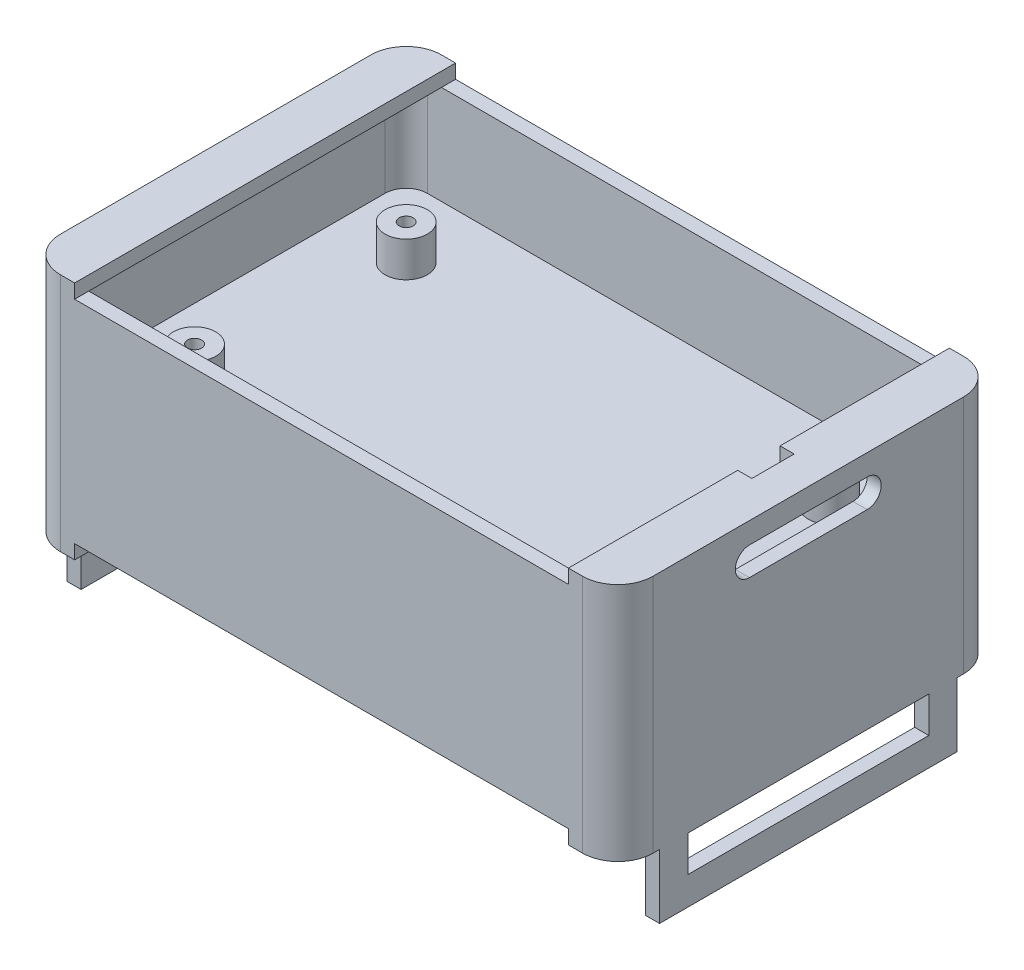
from build123d import *

# Parameters (mm, degrees)
EXTRUDE_THIN1_DEPTH      = 15
EXTRUDE_THIN1_DEPTH_BACK = 15
BOSS_EXTRUDE1_DEPTH      = 1
SKETCH3_R                = 3
SKETCH3_R_2              = 1
BOSS_EXTRUDE2_DEPTH      = 5
BOSS_EXTRUDE3_DEPTH      = 2
BOSS_EXTRUDE4_START      = -30
BOSS_EXTRUDE4_DEPTH      = 2
SKETCH5_W                = 34.167254682
SKETCH5_H                = 5.095662734
BOSS_EXTRUDE5_DEPTH      = 2
BOSS_EXTRUDE6_START      = -84
SKETCH5_3_W              = 34.167254682
SKETCH5_3_H              = 5.095662734
BOSS_EXTRUDE6_DEPTH      = 2
CUT_EXTRUDE1_DEPTH       = 85


with BuildPart() as part:
    # Sketch1 → Extrude-Thin1 (new body, two sides)
    with BuildSketch(Plane(origin=(0, 0, 0), x_dir=(1, 0, 0), z_dir=(0, 1, 0))) as extrude_thin1_sk:
        with BuildLine():
            Line((-42, 22), (-42, -22))
            ThreePointArc((-42, -22), (-40.535533906, -25.535533906), (-37, -27))
            Line((-37, -27), (37, -27))
            ThreePointArc((37, -27), (40.535533906, -25.535533906), (42, -22))
            Line((42, -22), (42, 22))
            ThreePointArc((42, 22), (40.535533906, 25.535533906), (37, 27))
            Line((37, 27), (-37, 27))
            ThreePointArc((-37, 27), (-40.535533906, 25.535533906), (-42, 22))
        make_face()
        with BuildLine():
            Line((-40, 22), (-40, -22))
            ThreePointArc((-40, -22), (-39.121320344, -24.121320344), (-37, -25))
            Line((-37, -25), (37, -25))
            ThreePointArc((37, -25), (39.121320344, -24.121320344), (40, -22))
            Line((40, -22), (40, 22))
            ThreePointArc((40, 22), (39.121320344, 24.121320344), (37, 25))
            Line((37, 25), (-37, 25))
            ThreePointArc((-37, 25), (-39.121320344, 24.121320344), (-40, 22))
        make_face(mode=Mode.SUBTRACT)
    extrude(amount=EXTRUDE_THIN1_DEPTH)
    extrude(extrude_thin1_sk.sketch, amount=-EXTRUDE_THIN1_DEPTH_BACK)

    # Sketch1_2 → Boss-Extrude1 (add)
    with BuildSketch(Plane(origin=(0, 0, 0), x_dir=(1, 0, 0), z_dir=(0, 1, 0))):
        with BuildLine():
            Line((-37, -25), (37, -25))
            ThreePointArc((37, -25), (39.121320344, -24.121320344), (40, -22))
            Line((40, -22), (40, 22))
            ThreePointArc((40, 22), (39.121320344, 24.121320344), (37, 25))
            Line((37, 25), (-37, 25))
            ThreePointArc((-37, 25), (-39.121320344, 24.121320344), (-40, 22))
            Line((-40, 22), (-40, -22))
            ThreePointArc((-40, -22), (-39.121320344, -24.121320344), (-37, -25))
        make_face()
    extrude(amount=BOSS_EXTRUDE1_DEPTH)

    # Sketch3 → Boss-Extrude2 (add)
    with BuildSketch(Plane(origin=(0, 1, 0), x_dir=(1, 0, 0), z_dir=(0, 1, 0))):
        with Locations((-30, 15)):
            Circle(SKETCH3_R)
        with Locations((-30, 15)):
            Circle(SKETCH3_R_2, mode=Mode.SUBTRACT)
        with Locations((30, 15)):
            Circle(SKETCH3_R)
        with Locations((30, 15)):
            Circle(SKETCH3_R_2, mode=Mode.SUBTRACT)
        with Locations((30, -15)):
            Circle(SKETCH3_R)
        with Locations((30, -15)):
            Circle(SKETCH3_R_2, mode=Mode.SUBTRACT)
        with Locations((-30, -15)):
            Circle(SKETCH3_R)
        with Locations((-30, -15)):
            Circle(SKETCH3_R_2, mode=Mode.SUBTRACT)
    extrude(amount=BOSS_EXTRUDE2_DEPTH)

    # Sketch4 → Boss-Extrude3 (add)
    with BuildSketch(Plane(origin=(0, 15, 0), x_dir=(1, 0, 0), z_dir=(0, 1, 0))):
        with BuildLine():
            Line((-35, 25), (-35, 27))
            Line((-35, 27), (-37, 27))
            ThreePointArc((-37, 27), (-40.535533906, 25.535533906), (-42, 22))
            Line((-42, 22), (-42, -22))
            ThreePointArc((-42, -22), (-40.535533906, -25.535533906), (-37, -27))
            Line((-37, -27), (-35, -27))
            Line((-35, -27), (-35, -25))
            Line((-35, -25), (-37, -25))
            ThreePointArc((-37, -25), (-39.121320344, -24.121320344), (-40, -22))
            Line((-40, -22), (-40, 22))
            ThreePointArc((-40, 22), (-39.121320344, 24.121320344), (-37, 25))
            Line((-37, 25), (-35, 25))
        make_face()
        with BuildLine():
            Line((-35, -25), (-35, 25))
            Line((-35, 25), (-37, 25))
            ThreePointArc((-37, 25), (-39.121320344, 24.121320344), (-40, 22))
            Line((-40, 22), (-40, -22))
            ThreePointArc((-40, -22), (-39.121320344, -24.121320344), (-37, -25))
            Line((-37, -25), (-35, -25))
        make_face()
        with BuildLine():
            Line((37, 25), (35, 25))
            Line((35, 25), (35, 3))
            Line((35, 3), (37, 3))
            Line((37, 3), (37, -3))
            Line((37, -3), (35, -3))
            Line((35, -3), (35, -25))
            Line((35, -25), (37, -25))
            ThreePointArc((37, -25), (39.121320344, -24.121320344), (40, -22))
            Line((40, -22), (40, 22))
            ThreePointArc((40, 22), (39.121320344, 24.121320344), (37, 25))
        make_face()
        with BuildLine():
            Line((37, 27), (35, 27))
            Line((35, 27), (35, 25))
            Line((35, 25), (37, 25))
            ThreePointArc((37, 25), (39.121320344, 24.121320344), (40, 22))
            Line((40, 22), (40, -22))
            ThreePointArc((40, -22), (39.121320344, -24.121320344), (37, -25))
            Line((37, -25), (35, -25))
            Line((35, -25), (35, -27))
            Line((35, -27), (37, -27))
            ThreePointArc((37, -27), (40.535533906, -25.535533906), (42, -22))
            Line((42, -22), (42, 22))
            ThreePointArc((42, 22), (40.535533906, 25.535533906), (37, 27))
        make_face()
    extrude(amount=BOSS_EXTRUDE3_DEPTH)

    # Sketch4_3 → Boss-Extrude4 (add)
    with BuildSketch(Plane(origin=(0, 15, 0), x_dir=(1, 0, 0), z_dir=(0, 1, 0)).offset(BOSS_EXTRUDE4_START)):
        with BuildLine():
            Line((-35, -25), (-35, 25))
            Line((-35, 25), (-37, 25))
            ThreePointArc((-37, 25), (-39.121320344, 24.121320344), (-40, 22))
            Line((-40, 22), (-40, -22))
            ThreePointArc((-40, -22), (-39.121320344, -24.121320344), (-37, -25))
            Line((-37, -25), (-35, -25))
        make_face()
        with BuildLine():
            Line((-35, 25), (-35, 27))
            Line((-35, 27), (-37, 27))
            ThreePointArc((-37, 27), (-40.535533906, 25.535533906), (-42, 22))
            Line((-42, 22), (-42, -22))
            ThreePointArc((-42, -22), (-40.535533906, -25.535533906), (-37, -27))
            Line((-37, -27), (-35, -27))
            Line((-35, -27), (-35, -25))
            Line((-35, -25), (-37, -25))
            ThreePointArc((-37, -25), (-39.121320344, -24.121320344), (-40, -22))
            Line((-40, -22), (-40, 22))
            ThreePointArc((-40, 22), (-39.121320344, 24.121320344), (-37, 25))
            Line((-37, 25), (-35, 25))
        make_face()
        with BuildLine():
            Line((37, 25), (35, 25))
            Line((35, 25), (35, 3))
            Line((35, 3), (37, 3))
            Line((37, 3), (37, -3))
            Line((37, -3), (35, -3))
            Line((35, -3), (35, -25))
            Line((35, -25), (37, -25))
            ThreePointArc((37, -25), (39.121320344, -24.121320344), (40, -22))
            Line((40, -22), (40, 22))
            ThreePointArc((40, 22), (39.121320344, 24.121320344), (37, 25))
        make_face()
        with BuildLine():
            Line((37, 27), (35, 27))
            Line((35, 27), (35, 25))
            Line((35, 25), (37, 25))
            ThreePointArc((37, 25), (39.121320344, 24.121320344), (40, 22))
            Line((40, 22), (40, -22))
            ThreePointArc((40, -22), (39.121320344, -24.121320344), (37, -25))
            Line((37, -25), (35, -25))
            Line((35, -25), (35, -27))
            Line((35, -27), (37, -27))
            ThreePointArc((37, -27), (40.535533906, -25.535533906), (42, -22))
            Line((42, -22), (42, 22))
            ThreePointArc((42, 22), (40.535533906, 25.535533906), (37, 27))
        make_face()
    extrude(amount=-BOSS_EXTRUDE4_DEPTH)

    # Sketch5 → Boss-Extrude5 (add)
    with BuildSketch(Plane.ZY.offset(42)):
        Polygon((21.083627341, -7.904337266), (-21.083627341, -7.904337266), (-21.083627341, -17), (-17.083627341, -17), (-17.083627341, -11.904337266), (17.083627341, -11.904337266), (17.083627341, -17), (21.083627341, -17), align=None)
        Polygon((-17.083627341, -17), (-21.083627341, -17), (-21.083627341, -26.095662734), (21.083627341, -26.095662734), (21.083627341, -17), (17.083627341, -17), (17.083627341, -22.095662734), (-17.083627341, -22.095662734), align=None)
        with Locations((0, -14.452168633)):
            Rectangle(SKETCH5_W, SKETCH5_H)
    extrude(amount=-BOSS_EXTRUDE5_DEPTH)

    # Sketch5_3 → Boss-Extrude6 (add)
    with BuildSketch(Plane.ZY.offset(42).offset(BOSS_EXTRUDE6_START)):
        Polygon((21.083627341, -7.904337266), (-21.083627341, -7.904337266), (-21.083627341, -17), (-17.083627341, -17), (-17.083627341, -11.904337266), (17.083627341, -11.904337266), (17.083627341, -17), (21.083627341, -17), align=None)
        with Locations((0, -14.452168633)):
            Rectangle(SKETCH5_3_W, SKETCH5_3_H)
        Polygon((-17.083627341, -17), (-21.083627341, -17), (-21.083627341, -26.095662734), (21.083627341, -26.095662734), (21.083627341, -17), (17.083627341, -17), (17.083627341, -22.095662734), (-17.083627341, -22.095662734), align=None)
    extrude(amount=BOSS_EXTRUDE6_DEPTH)

    # Sketch7 → Cut-Extrude1 (cut, through all)
    with BuildSketch(Plane(origin=(42, 0, 0), x_dir=(0, 0, -1), z_dir=(1, 0, 0))):
        with BuildLine():
            Line((-8.338334794, 14), (8.338334794, 14))
            ThreePointArc((8.338334794, 14), (10.338334794, 12), (8.338334794, 10))
            Line((8.338334794, 10), (-8.338334794, 10))
            ThreePointArc((-8.338334794, 10), (-10.338334794, 12), (-8.338334794, 14))
        make_face()
    extrude(amount=-CUT_EXTRUDE1_DEPTH, mode=Mode.SUBTRACT)


solid = part.part
